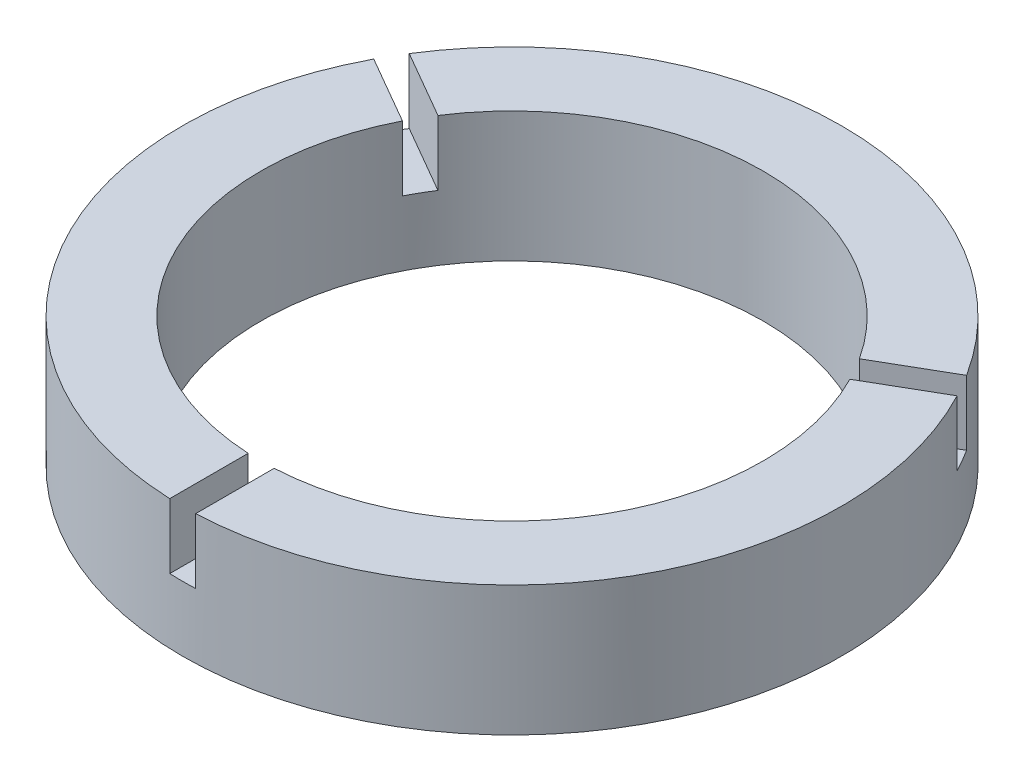
from build123d import *

# Parameters (mm, degrees)
SKETCH1_R               = 38.05
SKETCH1_R_2             = 29
BOSS_EXTRUDE1_DEPTH     = 15
SKETCH3_R               = 21.5
SKETCH3_R_2             = 18.5
SKETCH3_R_3             = 54.301992004
SKETCH3_R_4             = 51.301992004
SKETCH3_W               = 3
SKETCH3_H               = 32.801992004
CUT_EXTRUDE_THIN1_DEPTH = 7.5


with BuildPart() as part:
    # Sketch1 → Boss-Extrude1 (new body)
    with BuildSketch(Plane(origin=(0, 0, 0), x_dir=(1, 0, 0), z_dir=(0, 1, 0))):
        Circle(SKETCH1_R)
        Circle(SKETCH1_R_2, mode=Mode.SUBTRACT)
    extrude(amount=BOSS_EXTRUDE1_DEPTH)

    # Sketch3 → Cut-Extrude-Thin1 (cut)
    with BuildSketch(Plane(origin=(0, 15, 0), x_dir=(1, 0, 0), z_dir=(0, 1, 0))):
        Circle(SKETCH3_R)
        Circle(SKETCH3_R_2, mode=Mode.SUBTRACT)
        Circle(SKETCH3_R_3)
        Circle(SKETCH3_R_4, mode=Mode.SUBTRACT)
        with Locations((0, -36.400996002)):
            Rectangle(SKETCH3_W, SKETCH3_H)
        Polygon((-16.570508076, 11.299038106), (-44.977866446, 27.700034108), (-46.477866446, 25.101957897), (-18.070508076, 8.700961894), align=None)
        Polygon((18.070508076, 8.700961894), (46.477866446, 25.101957897), (44.977866446, 27.700034108), (16.570508076, 11.299038106), align=None)
    extrude(amount=-CUT_EXTRUDE_THIN1_DEPTH, mode=Mode.SUBTRACT)


solid = part.part
